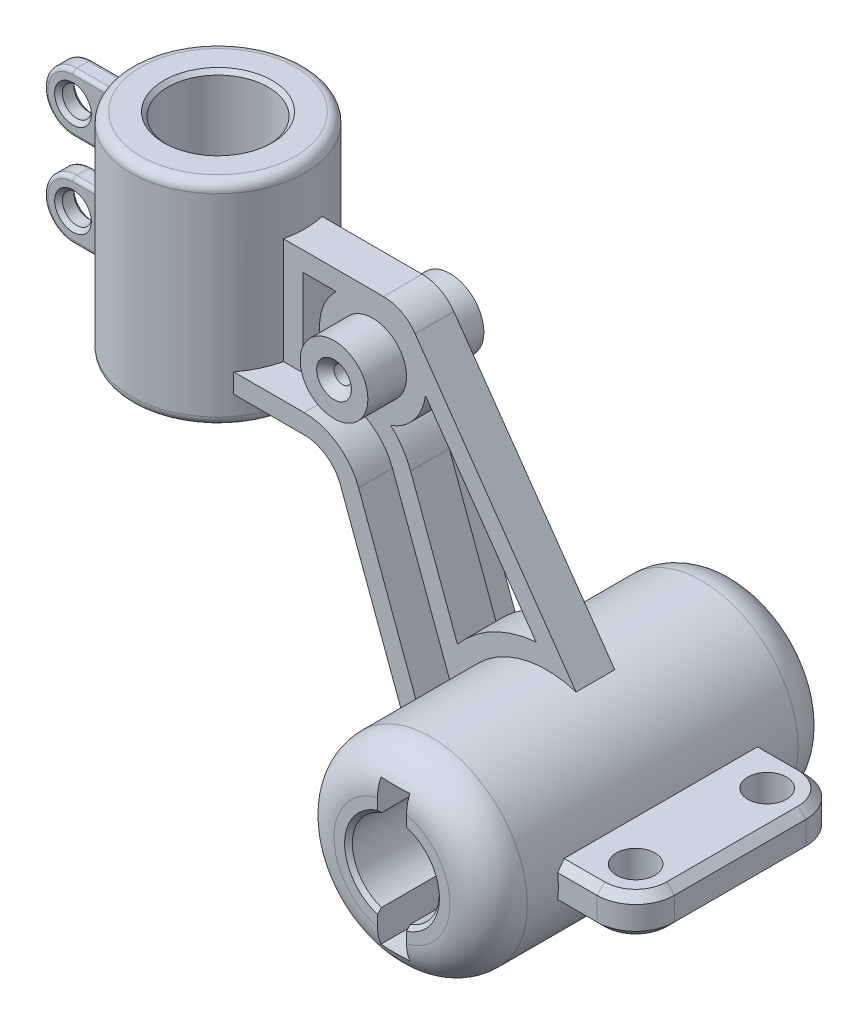
from build123d import *

# Parameters (mm, degrees)
SKETCH1_R                                            = 50
SKETCH1_R_2                                          = 22.5
BOSS_EXTRUDE1_DEPTH                                  = 90
FILLET1_R                                            = 20
BOSS_EXTRUDE2_START                                  = 95
SKETCH3_R                                            = 45
SKETCH3_R_2                                          = 26
BOSS_EXTRUDE2_DEPTH                                  = 110
FILLET2_R                                            = 5
BOSS_EXTRUDE3_DEPTH                                  = 10
FILLET3_R                                            = 20
BOSS_EXTRUDE5_DEPTH                                  = 27.5
CHAMFER1_SIZE                                        = 2
SKETCH6_W                                            = 15
SKETCH6_H                                            = 75
CUT_EXTRUDE1_DEPTH                                   = 354.624094265
CUT_EXTRUDE1_DEPTH_BACK                              = 354.624094265
CUT_EXTRUDE2_DEPTH                                   = 321.390386973
CUT_EXTRUDE2_DEPTH_BACK                              = 321.390386973
CUT_EXTRUDE3_DEPTH                                   = 321.390386973
CUT_EXTRUDE3_DEPTH_BACK                              = 321.390386973
SKETCH9_R                                            = 17.5
BOSS_EXTRUDE6_DEPTH                                  = 30
CSK_FOR_M8_HEX_SOCKET_COUNTERSUNK_CAP_SC_D           = 9
CSK_FOR_M8_HEX_SOCKET_COUNTERSUNK_CAP_SC_CSINK_D     = 17.92
CSK_FOR_M8_HEX_SOCKET_COUNTERSUNK_CAP_SC_CSINK_ANGLE = 90
RIB1_REACH                                           = 319.411
SKETCH13_WALL_W                                      = 731.822810122
SKETCH13_WALL_H                                      = 10
SKETCH14_R                                           = 10
BOSS_EXTRUDE8_DEPTH                                  = 10
CHAMFER2_SIZE                                        = 4
SKETCH15_R                                           = 7.5
BOSS_EXTRUDE9_DEPTH                                  = 5
FILLET4_R                                            = 2
CHAMFER3_SIZE                                        = 2


with BuildPart() as part:
    # Sketch1 → Boss-Extrude1 (new, symmetric)
    with BuildSketch(Plane.XY):
        with Locations(Location((0, 0, 0), (0, 0, 180))):
            Circle(SKETCH1_R)
        with Locations(Location((0, 0, 0), (0, 0, 180))):
            Circle(SKETCH1_R_2, mode=Mode.SUBTRACT)
    extrude(amount=BOSS_EXTRUDE1_DEPTH, both=True)

    # Fillet1
    fillet1_edges = [part.edges().sort_by_distance(p)[0] for p in [
        (50, 0, -90),
        (50, 0, 90),
    ]]
    fillet(fillet1_edges, radius=FILLET1_R)



with BuildPart() as body_2:
    # Sketch3 → Boss-Extrude2 (new body)
    with BuildSketch(Plane(origin=(0, 0, 0), x_dir=(1, 0, 0), z_dir=(0, 1, 0)).offset(BOSS_EXTRUDE2_START)):
        with Locations(Location((-180, 0, 0), (0, 0, 270))):
            Circle(SKETCH3_R)
        with Locations(Location((-180, 0, 0), (0, 0, 270))):
            Circle(SKETCH3_R_2, mode=Mode.SUBTRACT)
    extrude(amount=BOSS_EXTRUDE2_DEPTH)

    # Fillet2
    fillet2_edges = [body_2.edges().sort_by_distance(p)[0] for p in [
        (-180, 95, -45),
        (-180, 205, -45),
    ]]
    fillet(fillet2_edges, radius=FILLET2_R)


with BuildPart() as part_1:
    add(part.part)

    add(body_2.part)  # Boss-Extrude3 merges body 2
    # Sketch2 → Boss-Extrude3 (add, symmetric)
    with BuildSketch(Plane.XY):
        with BuildLine():
            Line((-46.89462071, -17.346312243), (-94, 110))
            Line((-94, 110), (-146, 110))
            Line((-146, 110), (-146, 175))
            Line((-146, 175), (-74, 175))
            Line((-74, 175), (15.178000732, 47.64061601))
            ThreePointArc((15.178000732, 47.64061601), (-36.156758796, 34.535326744), (-46.89462071, -17.346312243))
        make_face()
    extrude(amount=BOSS_EXTRUDE3_DEPTH, both=True)

    # Fillet3
    fillet3_edges = [part_1.edges().sort_by_distance(p)[0] for p in [
        (-74, 175, 0),
        (-94, 110, 0),
    ]]
    fillet(fillet3_edges, radius=FILLET3_R)

    # Sketch5 → Boss-Extrude5 (add, symmetric)
    with BuildSketch(Plane.XY):
        with BuildLine():
            Line((-89.168562576, 96.938524897), (-46.89462071, -17.346312243))
            Line((-46.89462071, -17.346312243), (-37.515696568, -13.877049795))
            Line((-37.515696568, -13.877049795), (-79.789638434, 100.407787346))
            ThreePointArc((-79.789638434, 100.407787346), (-90.783389253, 114.619439681), (-107.92641086, 120))
            Line((-107.92641086, 120), (-136.125178063, 120))
            Line((-136.125178063, 120), (-148.125178063, 120))
            Line((-148.125178063, 120), (-148.125178063, 110))
            Line((-148.125178063, 110), (-136.125178063, 110))
            Line((-136.125178063, 110), (-107.92641086, 110))
            ThreePointArc((-107.92641086, 110), (-96.497729789, 106.412959787), (-89.168562576, 96.938524897))
        make_face()
    extrude(amount=BOSS_EXTRUDE5_DEPTH, both=True)

    # Chamfer1
    chamfer1_edges = [part_1.edges().sort_by_distance(p)[0] for p in [
        (-180, 95, -26),
        (-180, 205, -26),
        (22.5, 0, -90),
        (22.5, 0, 90),
    ]]
    chamfer(chamfer1_edges, length=CHAMFER1_SIZE)

    # Sketch6 → Cut-Extrude1 (cut, two sides)
    with BuildSketch(Plane(origin=(0, 0, -90), x_dir=(-1, 0, 0), z_dir=(0, 0, -1))) as cut_extrude1_sk:
        Rectangle(SKETCH6_W, SKETCH6_H)
    extrude(amount=CUT_EXTRUDE1_DEPTH, mode=Mode.SUBTRACT)
    extrude(cut_extrude1_sk.sketch, amount=-CUT_EXTRUDE1_DEPTH_BACK, mode=Mode.SUBTRACT)

    # Sketch7 → Cut-Extrude2 (cut, two sides)
    with BuildSketch(Plane.XY.offset(10)) as cut_extrude2_sk:
        with BuildLine():
            Line((-5.506572108, 59.746779525), (-62.727859358, 141.467246854))
            ThreePointArc((-62.727859358, 141.467246854), (-68.523257729, 127.824449312), (-80.558272863, 119.171647581))
            ThreePointArc((-80.558272863, 119.171647581), (-74.595356611, 112.114267401), (-70.410714292, 103.877049795))
            Line((-70.410714292, 103.877049795), (-46.163588904, 38.326532057))
            ThreePointArc((-46.163588904, 38.326532057), (-27.967090216, 53.083348282), (-5.506572108, 59.746779525))
        make_face()
    extrude(amount=CUT_EXTRUDE2_DEPTH, mode=Mode.SUBTRACT)
    extrude(cut_extrude2_sk.sketch, amount=-CUT_EXTRUDE2_DEPTH_BACK, mode=Mode.SUBTRACT)

    # Sketch8 → Cut-Extrude3 (cut, two sides)
    with BuildSketch(Plane.XY.offset(10)) as cut_extrude3_sk:
        with BuildLine():
            Line((-108.874586088, 165), (-126.125178063, 165))
            Line((-126.125178063, 165), (-126.125178063, 130))
            Line((-126.125178063, 130), (-113.048861143, 130))
            ThreePointArc((-113.048861143, 130), (-117.306480127, 148.256707395), (-108.874586088, 165))
        make_face()
    extrude(amount=CUT_EXTRUDE3_DEPTH, mode=Mode.SUBTRACT)
    extrude(cut_extrude3_sk.sketch, amount=-CUT_EXTRUDE3_DEPTH_BACK, mode=Mode.SUBTRACT)

    # Sketch9 → Boss-Extrude6 (add, symmetric)
    with BuildSketch(Plane.XY):
        with Locations((-90, 145)):
            Circle(SKETCH9_R)
    extrude(amount=BOSS_EXTRUDE6_DEPTH, both=True)

    # CSK for M8 Hex Socket Countersunk Cap Screw1 (through all)
    with Locations(Plane.XY.offset(30)):
        with Locations((-90, 145)):
            CounterSinkHole(CSK_FOR_M8_HEX_SOCKET_COUNTERSUNK_CAP_SC_D / 2, CSK_FOR_M8_HEX_SOCKET_COUNTERSUNK_CAP_SC_CSINK_D / 2, counter_sink_angle=CSK_FOR_M8_HEX_SOCKET_COUNTERSUNK_CAP_SC_CSINK_ANGLE)

    # Sketch13 wall → Rib1 (add, up to next)
    with BuildSketch(Plane(origin=(-97.613239056, 73.612888952, 0), x_dir=(-0.642787609693, 0.766044443114, 0), z_dir=(-0.766044443114, -0.642787609693, 0)), mode=Mode.PRIVATE) as rib1_sk1:
        Rectangle(SKETCH13_WALL_W, SKETCH13_WALL_H)
    rib1_tool1 = extrude(rib1_sk1.sketch, amount=-RIB1_REACH, mode=Mode.PRIVATE) - part_1.part
    add(rib1_tool1.solids().sort_by_distance((-97.613239056, 73.612888952, 0))[0])

    # Sketch14 → Boss-Extrude8 (add, symmetric)
    with BuildSketch(Plane(origin=(0, 0, 0), x_dir=(1, 0, 0), z_dir=(0, 1, 0))):
        with BuildLine():
            Line((70, -54), (40, -54))
            Line((40, -54), (40, 54))
            Line((40, 54), (70, 54))
            ThreePointArc((70, 54), (84.142135624, 48.142135624), (90, 34))
            Line((90, 34), (90, -34))
            ThreePointArc((90, -34), (84.142135624, -48.142135624), (70, -54))
        make_face()
        with Locations(Location((70, 34, 0), (0, 0, 270))):
            Circle(SKETCH14_R, mode=Mode.SUBTRACT)
        with Locations(Location((70, -34, 0), (0, 0, 270))):
            Circle(SKETCH14_R, mode=Mode.SUBTRACT)
    extrude(amount=BOSS_EXTRUDE8_DEPTH, both=True)

    # Chamfer2
    chamfer2_edges = [part_1.edges().sort_by_distance(p)[0] for p in [
        (59.494897428, 10, 54),
        (84.142135624, 10, 48.142135624),
        (90, 10, 0),
        (84.142135624, 10, -48.142135624),
        (59.494897428, 10, -54),
        (59.494897428, -10, 54),
        (84.142135624, -10, 48.142135624),
        (90, -10, 0),
        (84.142135624, -10, -48.142135624),
        (59.494897428, -10, -54),
    ]]
    chamfer(chamfer2_edges, length=CHAMFER2_SIZE)

    # Sketch15 → Boss-Extrude9 (add, symmetric)
    with BuildSketch(Plane.XY):
        with BuildLine():
            Line((-217.5, 143), (-217.5, 113))
            Line((-217.5, 113), (-250, 113))
            ThreePointArc((-250, 113), (-265, 128), (-250, 143))
            Line((-250, 143), (-217.5, 143))
        make_face()
        with Locations((-250, 128)):
            Circle(SKETCH15_R, mode=Mode.SUBTRACT)
        with BuildLine():
            Line((-217.5, 161), (-250, 161))
            ThreePointArc((-250, 161), (-265, 176), (-250, 191))
            Line((-250, 191), (-217.5, 191))
            Line((-217.5, 191), (-217.5, 161))
        make_face()
        with Locations((-250, 176)):
            Circle(SKETCH15_R, mode=Mode.SUBTRACT)
    extrude(amount=BOSS_EXTRUDE9_DEPTH, both=True)

    # Fillet4
    fillet4_edges = [part_1.edges().sort_by_distance(p)[0] for p in [
        (-225, 113, 0),
        (-224.72135955, 128, -5),
        (-224.72135955, 128, 5),
        (-225, 143, 0),
        (-237.360679775, 143, 5),
        (-265, 128, 5),
        (-237.360679775, 113, 5),
        (-237.360679775, 143, -5),
        (-265, 128, -5),
        (-237.360679775, 113, -5),
        (-225, 161, 0),
        (-224.72135955, 176, -5),
        (-224.72135955, 176, 5),
        (-225, 191, 0),
        (-237.360679775, 191, 5),
        (-265, 176, 5),
        (-237.360679775, 161, 5),
        (-237.360679775, 191, -5),
        (-265, 176, -5),
        (-237.360679775, 161, -5),
    ]]
    fillet(fillet4_edges, radius=FILLET4_R)

    # Chamfer3
    chamfer3_edges = [part_1.edges().sort_by_distance(p)[0] for p in [
        (-257.5, 128, -5),
        (-257.5, 128, 5),
        (-257.5, 176, -5),
        (-257.5, 176, 5),
    ]]
    chamfer(chamfer3_edges, length=CHAMFER3_SIZE)


solid = part_1.part
